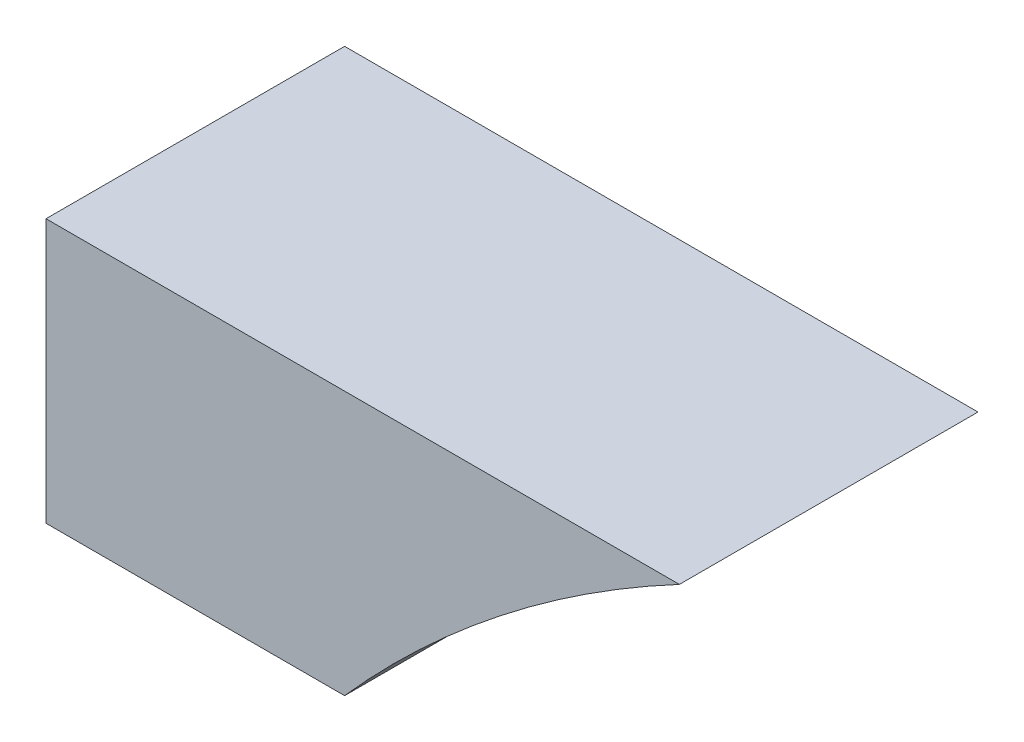
from build123d import *

# Parameters (mm, degrees)
EXTRUDE_1_DEPTH = 480
SCALE_1_SCALE   = 1.3


with BuildPart() as part:
    # 草图1 → 凸台-拉伸1 (new body)
    with BuildSketch(Plane.XY):
        with BuildLine():
            Line((-8158.198873592, 5112), (-7678.198873592, 5112))
            ThreePointArc((-7678.198873592, 5112), (-7531.058159836, 5261.115346452), (-7368.547684402, 5393.3126292))
            ThreePointArc((-7368.547684402, 5393.3126292), (-7256.775458313, 5468.670521429), (-7139.991111067, 5536))
            Line((-7139.991111067, 5536), (-7619.991111067, 5536))
            Line((-7619.991111067, 5536), (-8158.198873592, 5536))
            Line((-8158.198873592, 5536), (-8158.198873592, 5112))
        make_face()
    extrude(amount=EXTRUDE_1_DEPTH)


with BuildPart() as part_1:
    # 缩放比例1: scaled about (0, 0, 0)
    add(part.part.scale(SCALE_1_SCALE))


solid = part_1.part
